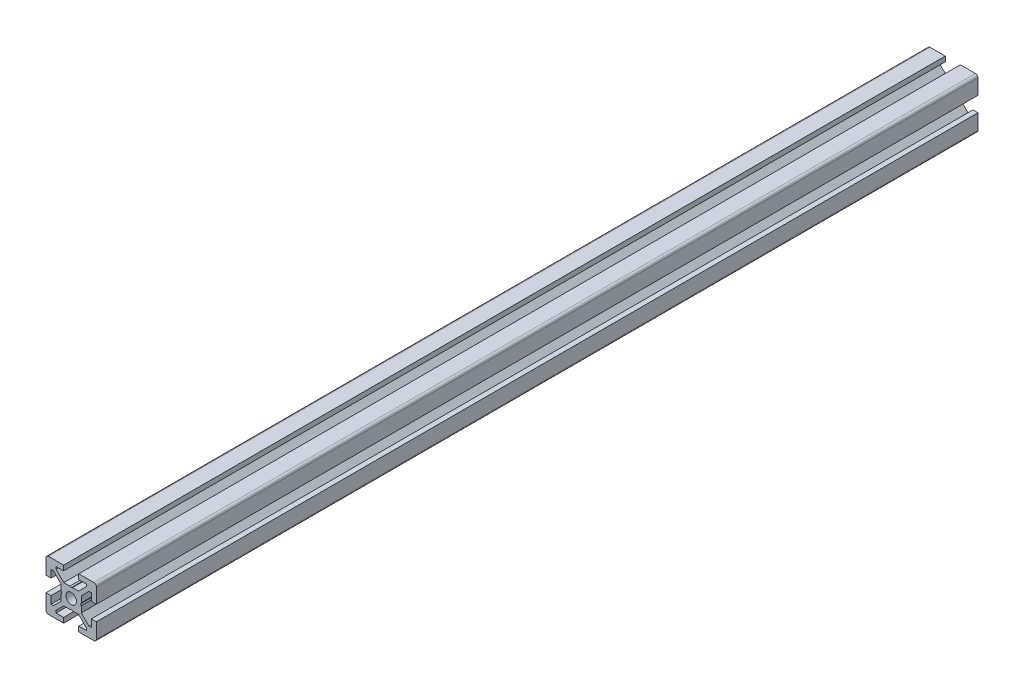
from build123d import *

# Parameters (mm, degrees)
EXTRUDE_1_DEPTH = 350
SKETCH_2_W      = 260
SKETCH_2_H      = 2.1


with BuildPart() as part:
    # ｽｹｯﾁ1 → ﾎﾞｽ - 押し出し1 (new body)
    with BuildSketch(Plane.XY):
        with BuildLine():
            Line((-10, -3), (-10, -9))
            ThreePointArc((-10, -9), (-9.707106781, -9.707106781), (-9, -10))
            Line((-9, -10), (-3, -10))
            Line((-3, -10), (-3, -8))
            Line((-3, -8), (-6, -8))
            Line((-6, -8), (-6, -7.060660172))
            Line((-6, -7.060660172), (-2.939339828, -4))
            Line((-2.939339828, -4), (-0.519615242, -4))
            Line((-0.519615242, -4), (0, -3.7))
            Line((0, -3.7), (0.519615242, -4))
            Line((0.519615242, -4), (2.939339828, -4))
            Line((2.939339828, -4), (6, -7.060660172))
            Line((6, -7.060660172), (6, -8))
            Line((6, -8), (3, -8))
            Line((3, -8), (3, -10))
            Line((3, -10), (9, -10))
            ThreePointArc((9, -10), (9.707106781, -9.707106781), (10, -9))
            Line((10, -9), (10, -3))
            Line((10, -3), (8, -3))
            Line((8, -3), (8, -6))
            Line((8, -6), (7.060660172, -6))
            Line((7.060660172, -6), (4, -2.939339828))
            Line((4, -2.939339828), (4, -0.519615242))
            Line((4, -0.519615242), (3.7, 0))
            Line((3.7, 0), (4, 0.519615242))
            Line((4, 0.519615242), (4, 2.939339828))
            Line((4, 2.939339828), (7.060660172, 6))
            Line((7.060660172, 6), (8, 6))
            Line((8, 6), (8, 3))
            Line((8, 3), (10, 3))
            Line((10, 3), (10, 9))
            ThreePointArc((10, 9), (9.707106781, 9.707106781), (9, 10))
            Line((9, 10), (3, 10))
            Line((3, 10), (3, 8))
            Line((3, 8), (6, 8))
            Line((6, 8), (6, 7.060660172))
            Line((6, 7.060660172), (2.939339828, 4))
            Line((2.939339828, 4), (0.519615242, 4))
            Line((0.519615242, 4), (0, 3.7))
            Line((0, 3.7), (-0.519615242, 4))
            Line((-0.519615242, 4), (-2.939339828, 4))
            Line((-2.939339828, 4), (-6, 7.060660172))
            Line((-6, 7.060660172), (-6, 8))
            Line((-6, 8), (-3, 8))
            Line((-3, 8), (-3, 10))
            Line((-3, 10), (-9, 10))
            ThreePointArc((-9, 10), (-9.707106781, 9.707106781), (-10, 9))
            Line((-10, 9), (-10, 3))
            Line((-10, 3), (-8, 3))
            Line((-8, 3), (-8, 6))
            Line((-8, 6), (-7.060660172, 6))
            Line((-7.060660172, 6), (-4, 2.939339828))
            Line((-4, 2.939339828), (-4, 0.519615242))
            Line((-4, 0.519615242), (-3.7, 0))
            Line((-3.7, 0), (-4, -0.519615242))
            Line((-4, -0.519615242), (-4, -2.939339828))
            Line((-4, -2.939339828), (-7.060660172, -6))
            Line((-7.060660172, -6), (-8, -6))
            Line((-8, -6), (-8, -3))
            Line((-8, -3), (-10, -3))
        make_face()
    extrude(amount=-EXTRUDE_1_DEPTH)

    # ｽｹｯﾁ2 → ｶｯﾄ - 回転1 (revolve, cut)
    with BuildSketch(Plane(origin=(0, 0, 0), x_dir=(0, 0, -1), z_dir=(1, 0, 0))):
        with Locations((130, 1.05)):
            Rectangle(SKETCH_2_W, SKETCH_2_H)
    revolve(axis=Axis((0, 0, -260), (0, 0, 1)), mode=Mode.SUBTRACT)


solid = part.part
